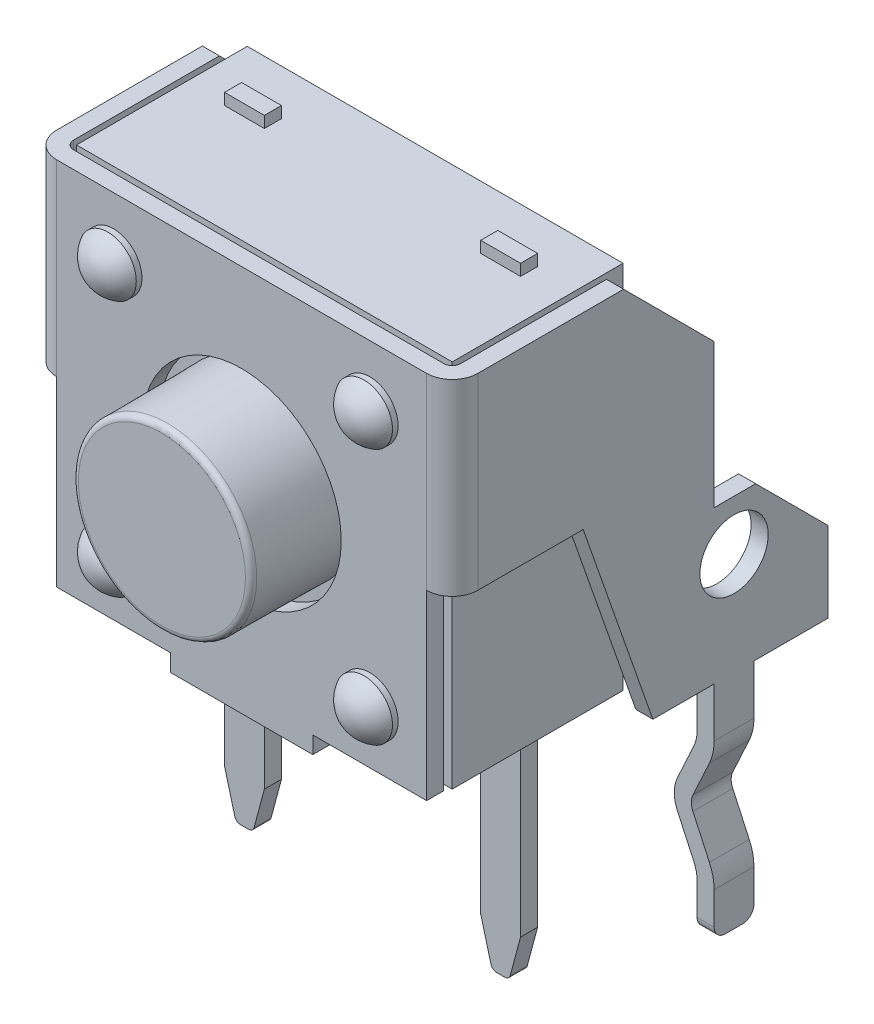
from build123d import *

# Parameters (mm, degrees)
EXTRUDE_THIN1_DEPTH          = 6.8
SKETCH2_R                    = 0.6
CUT_EXTRUDE1_DEPTH           = 13.518086915
CUT_EXTRUDE2_REACH           = 13.606
SKETCH3_R                    = 1.75
EXTRUDE_THIN2_DEPTH          = 0.35
FILLET1_R                    = 0.2
SKETCH6_R                    = 0.5
EXTRUDE1_DEPTH               = 0.1
DOME1_FACE_RADIUS            = 0.5
DOME1_HEIGHT                 = 0.3
LPATTERN1_COUNT              = 2
LPATTERN1_PITCH              = 4.5
LPATTERN1_COUNT_DIR2         = 2
LPATTERN1_PITCH_DIR2         = 4.5
LPATTERN1_COPY_1_FACE_RADIUS = 0.5
LPATTERN1_COPY_1_HEIGHT      = 0.3
LPATTERN1_COPY_2_FACE_RADIUS = 0.5
LPATTERN1_COPY_2_HEIGHT      = 0.3
LPATTERN1_COPY_3_FACE_RADIUS = 0.5
LPATTERN1_COPY_3_HEIGHT      = 0.3
SKETCH7_W                    = 6.6
SKETCH7_H                    = 3
EXTRUDE2_DEPTH               = 6.5
EXTRUDE3_START               = 2.5
SKETCH8_R                    = 1.6
EXTRUDE3_DEPTH               = 3.85
EXTRUDE3_TAPER               = 0.5
FILLET2_R                    = 0.1
EXTRUDE4_DEPTH               = 0.15
FILLET3_R                    = 0.1
FILLET1_OF_MIRROR1_R         = 0.2
FILLET3_OF_MIRROR2_R         = 0.1
EXTRUDE5_REACH               = 13.538
SKETCH10_R                   = 0.4
BODY_MOVE_COPY1_ANGLE        = 180


with BuildPart() as part:
    # Sketch1 → Extrude-Thin1 (new body)
    with BuildSketch(Plane(origin=(0, 2, 0), x_dir=(-1, 0, 0), z_dir=(0, 1, 0))):
        with BuildLine():
            Line((-3.7, 1.65), (-3.7, -4.5))
            ThreePointArc((-3.7, -4.5), (-3.568198052, -4.818198052), (-3.25, -4.95))
            Line((-3.25, -4.95), (3.25, -4.95))
            ThreePointArc((3.25, -4.95), (3.568198052, -4.818198052), (3.7, -4.5))
            Line((3.7, -4.5), (3.7, 1.65))
            Line((3.7, 1.65), (3.4, 1.65))
            Line((3.4, 1.65), (3.4, -4.5))
            ThreePointArc((3.4, -4.5), (3.356066017, -4.606066017), (3.25, -4.65))
            Line((3.25, -4.65), (-3.25, -4.65))
            ThreePointArc((-3.25, -4.65), (-3.356066017, -4.606066017), (-3.4, -4.5))
            Line((-3.4, -4.5), (-3.4, 1.65))
            Line((-3.4, 1.65), (-3.7, 1.65))
        make_face()
    extrude(amount=EXTRUDE_THIN1_DEPTH)

    # Sketch2 → Cut-Extrude1 (cut, through all)
    with BuildSketch(Plane.ZY.offset(3.7)):
        with Locations((0, 3.8)):
            Circle(SKETCH2_R)
        Polygon((-4.65, 2), (-4.65, 5.5), (-2.65, 5.5), (-1.425, 2), align=None)
        Polygon((-1.939540106, 8.8), (-0.35, 7.210459894), (-0.35, 4.682211917), (0.379967393, 4.682211917), (1.65, 3.41217931), (1.65, 8.8), align=None)
    extrude(amount=-CUT_EXTRUDE1_DEPTH, mode=Mode.SUBTRACT)

    # Sketch3 → Cut-Extrude2 (cut, up to next)
    with BuildSketch(Plane(origin=(0, 0, -4.95), x_dir=(-1, 0, 0), z_dir=(0, 0, -1)), mode=Mode.PRIVATE) as cut_extrude2_sk1:
        with Locations((0, 5.5)):
            Circle(SKETCH3_R)
    cut_extrude2_tool1 = extrude(cut_extrude2_sk1.sketch, amount=-CUT_EXTRUDE2_REACH, mode=Mode.PRIVATE) & part.part
    # Sketch3 → Cut-Extrude2 (cut, up to next)
    with BuildSketch(Plane(origin=(0, 0, -4.95), x_dir=(-1, 0, 0), z_dir=(0, 0, -1)), mode=Mode.PRIVATE) as cut_extrude2_sk2:
        Polygon((3.7, 5.5), (3.25, 5.5), (3.25, 2.3), (1.25, 2.3), (1.25, 2), (3.7, 2), align=None)
    cut_extrude2_tool2 = extrude(cut_extrude2_sk2.sketch, amount=-CUT_EXTRUDE2_REACH, mode=Mode.PRIVATE) & part.part
    # Sketch3 → Cut-Extrude2 (cut, up to next)
    with BuildSketch(Plane(origin=(0, 0, -4.95), x_dir=(-1, 0, 0), z_dir=(0, 0, -1)), mode=Mode.PRIVATE) as cut_extrude2_sk3:
        Polygon((-3.7, 5.5), (-3.25, 5.5), (-3.25, 2.3), (-1.25, 2.3), (-1.25, 2), (-3.7, 2), align=None)
    cut_extrude2_tool3 = extrude(cut_extrude2_sk3.sketch, amount=-CUT_EXTRUDE2_REACH, mode=Mode.PRIVATE) & part.part
    add(cut_extrude2_tool1.solids().sort_by_distance((0, 5.5, -4.95))[0], mode=Mode.SUBTRACT)
    add(cut_extrude2_tool2.solids().sort_by_distance((-3.475, 5.457277, -4.95))[0], mode=Mode.SUBTRACT)
    add(cut_extrude2_tool3.solids().sort_by_distance((3.475, 5.457277, -4.95))[0], mode=Mode.SUBTRACT)

    # Sketch5 → Extrude-Thin2 (add, symmetric)
    with BuildSketch(Plane.XY):
        with BuildLine():
            Line((-3.4, 2), (-3.4, 1.131534156))
            ThreePointArc((-3.4, 1.131534156), (-3.386082006, 1.003051153), (-3.344973726, 0.880528901))
            Line((-3.344973726, 0.880528901), (-3.055026274, 0.251005255))
            ThreePointArc((-3.055026274, 0.251005255), (-3, 0), (-3.055026274, -0.251005255))
            Line((-3.055026274, -0.251005255), (-3.344973726, -0.880528901))
            ThreePointArc((-3.344973726, -0.880528901), (-3.386082006, -1.003051153), (-3.4, -1.131534156))
            Line((-3.4, -1.131534156), (-3.4, -1.9))
            Line((-3.4, -1.9), (-3.7, -1.9))
            Line((-3.7, -1.9), (-3.7, -1.131534156))
            ThreePointArc((-3.7, -1.131534156), (-3.679123009, -0.938809651), (-3.617460589, -0.755026274))
            Line((-3.617460589, -0.755026274), (-3.327513137, -0.125502627))
            ThreePointArc((-3.327513137, -0.125502627), (-3.3, 0), (-3.327513137, 0.125502627))
            Line((-3.327513137, 0.125502627), (-3.617460589, 0.755026274))
            ThreePointArc((-3.617460589, 0.755026274), (-3.679123009, 0.938809651), (-3.7, 1.131534156))
            Line((-3.7, 1.131534156), (-3.7, 2))
            Line((-3.7, 2), (-3.4, 2))
        make_face()
    extrude_thin2 = extrude(amount=EXTRUDE_THIN2_DEPTH, both=True)

    # Fillet1
    fillet1_edges = [part.edges().sort_by_distance(p)[0] for p in [
        (-3.55, -1.9, 0.35),
        (-3.55, -1.9, -0.35),
    ]]
    fillet(fillet1_edges, radius=FILLET1_R)

    # Sketch6 → Extrude1 (add)
    with BuildSketch(Plane(origin=(0, 0, -4.95), x_dir=(-1, 0, 0), z_dir=(0, 0, -1))):
        with Locations(Location((-2.25, 3.25, 0), (0, 0, 180))):
            Circle(SKETCH6_R)
    extrude1 = extrude(amount=EXTRUDE1_DEPTH)

    # Dome1: a dome of height H over a round flat face of radius A is a cap of a sphere of radius (A * A + H * H) / (2 * H)
    dome1_r = (DOME1_FACE_RADIUS * DOME1_FACE_RADIUS + DOME1_HEIGHT * DOME1_HEIGHT) / (2 * DOME1_HEIGHT)
    dome1_base = Plane((2.25, 3.25, -5.05), z_dir=(0, 0, -1))
    with Locations(dome1_base.offset(DOME1_HEIGHT - dome1_r)):
        dome1_ball = Sphere(dome1_r, mode=Mode.PRIVATE)
    add(split(dome1_ball, bisect_by=dome1_base, keep=Keep.TOP, mode=Mode.PRIVATE))

    # LPattern1: Extrude1 2 × 2
    with Locations(*[(-j * LPATTERN1_PITCH_DIR2, i * LPATTERN1_PITCH, 0) for i in range(LPATTERN1_COUNT) for j in range(LPATTERN1_COUNT_DIR2) if (i, j) != (0, 0)]):
        add(extrude1)

    # LPattern1 copy 1: a dome of height H over a round flat face of radius A is a cap of a sphere of radius (A * A + H * H) / (2 * H)
    lpattern1_copy_1_r = (LPATTERN1_COPY_1_FACE_RADIUS * LPATTERN1_COPY_1_FACE_RADIUS + LPATTERN1_COPY_1_HEIGHT * LPATTERN1_COPY_1_HEIGHT) / (2 * LPATTERN1_COPY_1_HEIGHT)
    lpattern1_copy_1_base = Plane((-2.25, 3.25, -5.05), z_dir=(0, 0, -1))
    with Locations(lpattern1_copy_1_base.offset(LPATTERN1_COPY_1_HEIGHT - lpattern1_copy_1_r)):
        lpattern1_copy_1_ball = Sphere(lpattern1_copy_1_r, mode=Mode.PRIVATE)
    add(split(lpattern1_copy_1_ball, bisect_by=lpattern1_copy_1_base, keep=Keep.TOP, mode=Mode.PRIVATE))

    # LPattern1 copy 2: a dome of height H over a round flat face of radius A is a cap of a sphere of radius (A * A + H * H) / (2 * H)
    lpattern1_copy_2_r = (LPATTERN1_COPY_2_FACE_RADIUS * LPATTERN1_COPY_2_FACE_RADIUS + LPATTERN1_COPY_2_HEIGHT * LPATTERN1_COPY_2_HEIGHT) / (2 * LPATTERN1_COPY_2_HEIGHT)
    lpattern1_copy_2_base = Plane((2.25, 7.75, -5.05), z_dir=(0, 0, -1))
    with Locations(lpattern1_copy_2_base.offset(LPATTERN1_COPY_2_HEIGHT - lpattern1_copy_2_r)):
        lpattern1_copy_2_ball = Sphere(lpattern1_copy_2_r, mode=Mode.PRIVATE)
    add(split(lpattern1_copy_2_ball, bisect_by=lpattern1_copy_2_base, keep=Keep.TOP, mode=Mode.PRIVATE))

    # LPattern1 copy 3: a dome of height H over a round flat face of radius A is a cap of a sphere of radius (A * A + H * H) / (2 * H)
    lpattern1_copy_3_r = (LPATTERN1_COPY_3_FACE_RADIUS * LPATTERN1_COPY_3_FACE_RADIUS + LPATTERN1_COPY_3_HEIGHT * LPATTERN1_COPY_3_HEIGHT) / (2 * LPATTERN1_COPY_3_HEIGHT)
    lpattern1_copy_3_base = Plane((-2.25, 7.75, -5.05), z_dir=(0, 0, -1))
    with Locations(lpattern1_copy_3_base.offset(LPATTERN1_COPY_3_HEIGHT - lpattern1_copy_3_r)):
        lpattern1_copy_3_ball = Sphere(lpattern1_copy_3_r, mode=Mode.PRIVATE)
    add(split(lpattern1_copy_3_ball, bisect_by=lpattern1_copy_3_base, keep=Keep.TOP, mode=Mode.PRIVATE))

    # Mirror1: Extrude-Thin2 across plane
    add(extrude_thin2.mirror(Plane(origin=(0, 0, 0), x_dir=(0, 0, 1), z_dir=(1, 0, 0))))

    # Fillet1 of Mirror1
    fillet1_of_mirror1_edges = [part.edges().sort_by_distance(p)[0] for p in [
        (3.55, -1.9, 0.35),
        (3.55, -1.9, -0.35),
    ]]
    fillet(fillet1_of_mirror1_edges, radius=FILLET1_OF_MIRROR1_R)

    # Sketch10 → Extrude5 (add, up to next)
    with BuildSketch(Plane(origin=(0, 0, -4.55), x_dir=(-1, 0, 0), z_dir=(0, 0, -1)), mode=Mode.PRIVATE) as extrude5_sk1:
        with Locations(Location((-2.25, 7.75, 0), (0, 0, 180))):
            Circle(SKETCH10_R)
    extrude5_tool1 = extrude(extrude5_sk1.sketch, amount=EXTRUDE5_REACH, mode=Mode.PRIVATE) - part.part
    # Sketch10 → Extrude5 (add, up to next)
    with BuildSketch(Plane(origin=(0, 0, -4.55), x_dir=(-1, 0, 0), z_dir=(0, 0, -1)), mode=Mode.PRIVATE) as extrude5_sk2:
        with Locations(Location((2.25, 7.75, 0), (0, 0, 180))):
            Circle(SKETCH10_R)
    extrude5_tool2 = extrude(extrude5_sk2.sketch, amount=EXTRUDE5_REACH, mode=Mode.PRIVATE) - part.part
    # Sketch10 → Extrude5 (add, up to next)
    with BuildSketch(Plane(origin=(0, 0, -4.55), x_dir=(-1, 0, 0), z_dir=(0, 0, -1)), mode=Mode.PRIVATE) as extrude5_sk3:
        with Locations(Location((-2.25, 3.25, 0), (0, 0, 180))):
            Circle(SKETCH10_R)
    extrude5_tool3 = extrude(extrude5_sk3.sketch, amount=EXTRUDE5_REACH, mode=Mode.PRIVATE) - part.part
    # Sketch10 → Extrude5 (add, up to next)
    with BuildSketch(Plane(origin=(0, 0, -4.55), x_dir=(-1, 0, 0), z_dir=(0, 0, -1)), mode=Mode.PRIVATE) as extrude5_sk4:
        with Locations(Location((2.25, 3.25, 0), (0, 0, 180))):
            Circle(SKETCH10_R)
    extrude5_tool4 = extrude(extrude5_sk4.sketch, amount=EXTRUDE5_REACH, mode=Mode.PRIVATE) - part.part


with BuildPart() as body_2:
    # Sketch7 → Extrude2 (new body)
    with BuildSketch(Plane(origin=(0, 8.8, 0), x_dir=(-1, 0, 0), z_dir=(0, 1, 0))):
        with Locations((0, -3.05)):
            Rectangle(SKETCH7_W, SKETCH7_H)
    extrude(amount=-EXTRUDE2_DEPTH)

    # Sketch8 → Extrude3 (add)
    with BuildSketch(Plane(origin=(0, 0, 0), x_dir=(-1, 0, 0), z_dir=(0, 0, -1)).offset(EXTRUDE3_START)):
        with Locations((0, 5.5)):
            Circle(SKETCH8_R)
    extrude(amount=EXTRUDE3_DEPTH, taper=EXTRUDE3_TAPER)

    # Fillet2
    fillet2_edges = [body_2.edges().sort_by_distance(p)[0] for p in [
        (1.566401559, 5.5, -6.35),
    ]]
    fillet(fillet2_edges, radius=FILLET2_R)

    # Sketch9 → Extrude4 (add, symmetric)
    with BuildSketch(Plane(origin=(0, 0, -2.5), x_dir=(-1, 0, 0), z_dir=(0, 0, -1))):
        Polygon((2.6, 9), (1.9, 9), (1.9, -1.25), (2.100961894, -2), (2.399038106, -2), (2.6, -1.25), align=None)
    extrude4 = extrude(amount=EXTRUDE4_DEPTH, both=True)

    # Fillet3
    fillet3_edges = [body_2.edges().sort_by_distance(p)[0] for p in [
        (-2.100961894, -2, -2.5),
        (-2.399038106, -2, -2.5),
    ]]
    fillet(fillet3_edges, radius=FILLET3_R)

    # Mirror2: Extrude4 across plane
    add(extrude4.mirror(Plane(origin=(0, 0, 0), x_dir=(0, 0, 1), z_dir=(1, 0, 0))))

    # Fillet3 of Mirror2
    fillet3_of_mirror2_edges = [body_2.edges().sort_by_distance(p)[0] for p in [
        (2.100961894, -2, -2.5),
        (2.399038106, -2, -2.5),
    ]]
    fillet(fillet3_of_mirror2_edges, radius=FILLET3_OF_MIRROR2_R)


with BuildPart() as part_1:
    add(part.part)

    add(body_2.part)  # Extrude5 merges body 2
    add(extrude5_tool1.solids().sort_by_distance((2.25, 7.75, -4.55))[0])
    add(extrude5_tool2.solids().sort_by_distance((-2.25, 7.75, -4.55))[0])
    add(extrude5_tool3.solids().sort_by_distance((2.25, 3.25, -4.55))[0])
    add(extrude5_tool4.solids().sort_by_distance((-2.25, 3.25, -4.55))[0])


with BuildPart() as part_2:
    # Body-Move_Copy1: moved
    add(part_1.part.rotate(Axis((0, 0, 0), (0, 1, 0)), BODY_MOVE_COPY1_ANGLE))


with BuildPart() as part_3:
    # Body-Move_Copy2: moved
    add(part_2.part.moved(Location((0, -2, 0))))


solid = part_3.part
